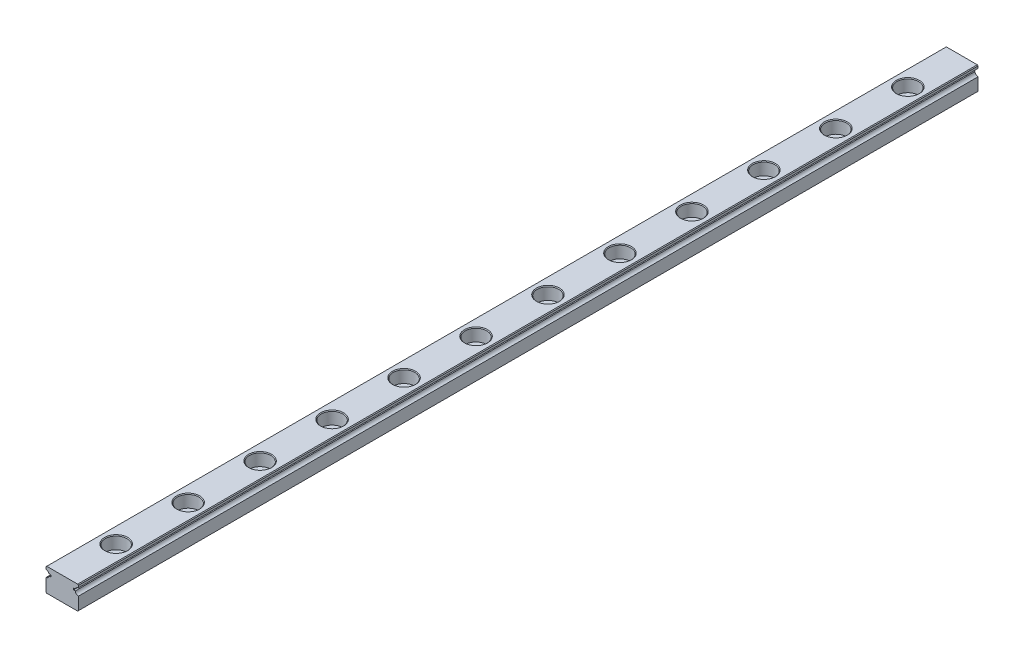
from build123d import *

# Parameters (mm, degrees)
EXTRUDE1_DEPTH             = 250
EXTRUDE2_REACH             = 252.125
SKETCH2_R                  = 1.75
SKETCH_R                   = 3
SKETCH_R_2                 = 1.75
EXTRUDE4_DEPTH             = 3.5
CHAMFER1_SIZE              = 0.2
LPATTERN1_COUNT            = 12
LPATTERN1_PITCH            = 20
CHAMFER1_OF_LPATTERN1_SIZE = 0.2


with BuildPart() as part:
    # Sketch1 → Extrude1 (new body)
    with BuildSketch(Plane.XY):
        with BuildLine():
            Line((-4.3, -3.25), (4.3, -3.25))
            Line((4.3, -3.25), (4.5, -3.05))
            Line((4.5, -3.05), (4.5, 0.455012563))
            ThreePointArc((4.5, 0.455012563), (3.924845827, 0.712323349), (3.617735397, 1.2625))
            Line((3.617735397, 1.2625), (3.15008224, 1.2625))
            Line((3.15008224, 1.2625), (3.15008224, 1.7625))
            Line((3.15008224, 1.7625), (3.65008224, 1.7625))
            ThreePointArc((3.65008224, 1.7625), (3.973877727, 2.229724887), (4.5, 2.444987437))
            Line((4.5, 2.444987437), (4.5, 3.05))
            Line((4.5, 3.05), (4.3, 3.25))
            Line((4.3, 3.25), (-4.3, 3.25))
            Line((-4.3, 3.25), (-4.5, 3.05))
            Line((-4.5, 3.05), (-4.5, 2.444987437))
            ThreePointArc((-4.5, 2.444987437), (-3.973877727, 2.229724887), (-3.65008224, 1.7625))
            Line((-3.65008224, 1.7625), (-3.15008224, 1.7625))
            Line((-3.15008224, 1.7625), (-3.15008224, 1.2625))
            Line((-3.15008224, 1.2625), (-3.617735397, 1.2625))
            ThreePointArc((-3.617735397, 1.2625), (-3.924845827, 0.712323349), (-4.5, 0.455012563))
            Line((-4.5, 0.455012563), (-4.5, -3.05))
            Line((-4.5, -3.05), (-4.3, -3.25))
        make_face()
    extrude(amount=EXTRUDE1_DEPTH)

    # Sketch2 → Extrude2 (cut, up to next)
    with BuildSketch(Plane(origin=(0, 3.25, 0), x_dir=(1, 0, 0), z_dir=(0, 1, 0)), mode=Mode.PRIVATE) as extrude2_sk1:
        with Locations((0, -15)):
            Circle(SKETCH2_R)
    extrude2_tool1 = extrude(extrude2_sk1.sketch, amount=-EXTRUDE2_REACH, mode=Mode.PRIVATE) & part.part
    extrude2 = extrude2_tool1.solids().sort_by_distance((0, 3.25, 15))[0]
    add(extrude2, mode=Mode.SUBTRACT)

    # Sketch → Extrude4 (cut)
    with BuildSketch(Plane(origin=(0, 3.25, 0), x_dir=(1, 0, 0), z_dir=(0, 1, 0))):
        with Locations((0, -15)):
            Circle(SKETCH_R)
        with Locations((0, -15)):
            Circle(SKETCH_R_2, mode=Mode.SUBTRACT)
    extrude4 = extrude(amount=-EXTRUDE4_DEPTH, mode=Mode.SUBTRACT)

    # Chamfer1
    chamfer1_edges = [part.edges().sort_by_distance(p)[0] for p in [
        (-1.75, -3.25, 15),
        (-3, 3.25, 15),
    ]]
    chamfer(chamfer1_edges, length=CHAMFER1_SIZE)

    # LPattern1: Extrude2, Extrude4 ×12
    with Locations(*[(0, 0, i * LPATTERN1_PITCH) for i in range(1, LPATTERN1_COUNT)]):
        add(extrude2, mode=Mode.SUBTRACT)
        add(extrude4, mode=Mode.SUBTRACT)

    # Chamfer1 of LPattern1
    chamfer1_of_lpattern1_edges = [part.edges().sort_by_distance(p)[0] for p in [
        (-1.75, -3.25, 35),
        (-3, 3.25, 35),
        (-1.75, -3.25, 55),
        (-3, 3.25, 55),
        (-1.75, -3.25, 75),
        (-3, 3.25, 75),
        (-1.75, -3.25, 95),
        (-3, 3.25, 95),
        (-1.75, -3.25, 115),
        (-3, 3.25, 115),
        (-1.75, -3.25, 135),
        (-3, 3.25, 135),
        (-1.75, -3.25, 155),
        (-3, 3.25, 155),
        (-1.75, -3.25, 175),
        (-3, 3.25, 175),
        (-1.75, -3.25, 195),
        (-3, 3.25, 195),
        (-1.75, -3.25, 215),
        (-3, 3.25, 215),
        (-1.75, -3.25, 235),
        (-3, 3.25, 235),
    ]]
    chamfer(chamfer1_of_lpattern1_edges, length=CHAMFER1_OF_LPATTERN1_SIZE)


solid = part.part
